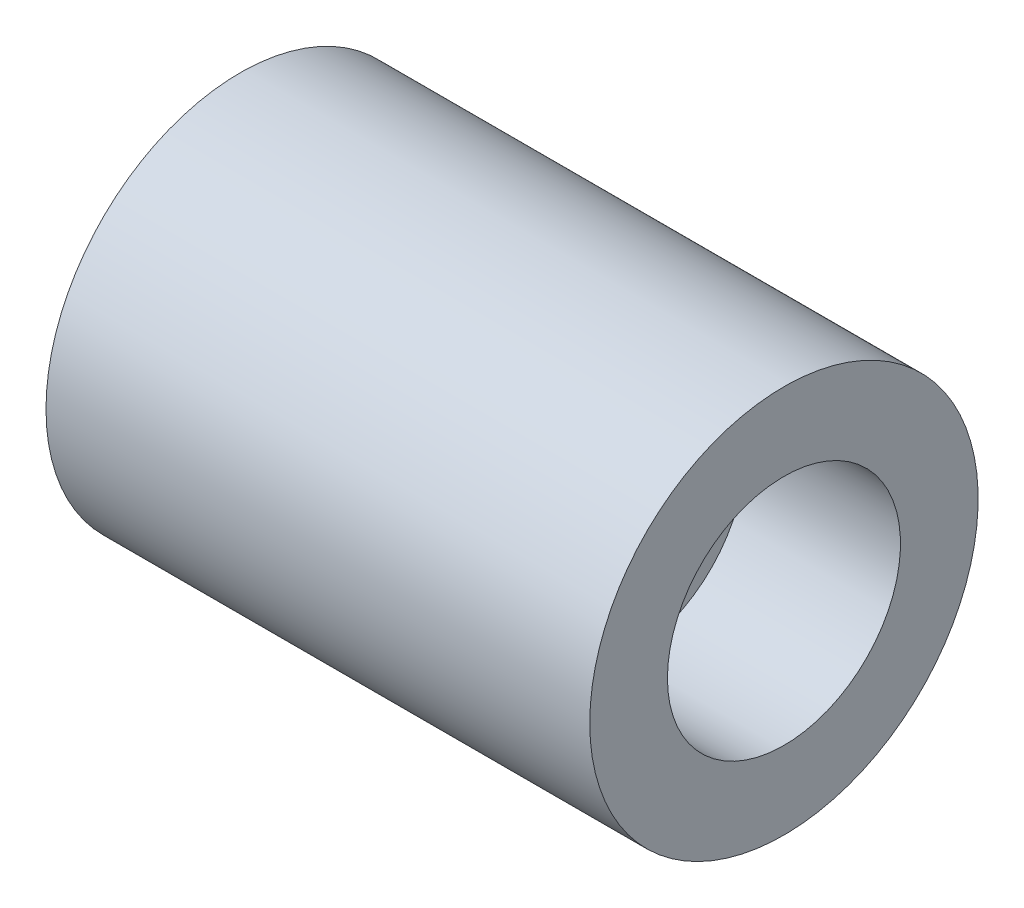
from build123d import *


with BuildPart() as part:
    # Sketch1 → Revolve4 (revolve)
    with BuildSketch(Plane.XY, mode=Mode.PRIVATE) as revolve4_sk:
        Polygon((-20, 50), (-20, 0), (0, 0), (0, 10), (80, 10), (80, 30), (120, 30), (120, 50), align=None)
    revolve(revolve4_sk.sketch.rotate(Axis((-155.22847078, 0, 0), (1, 0, 0)), 90), axis=Axis((-155.22847078, 0, 0), (1, 0, 0)))


solid = part.part
